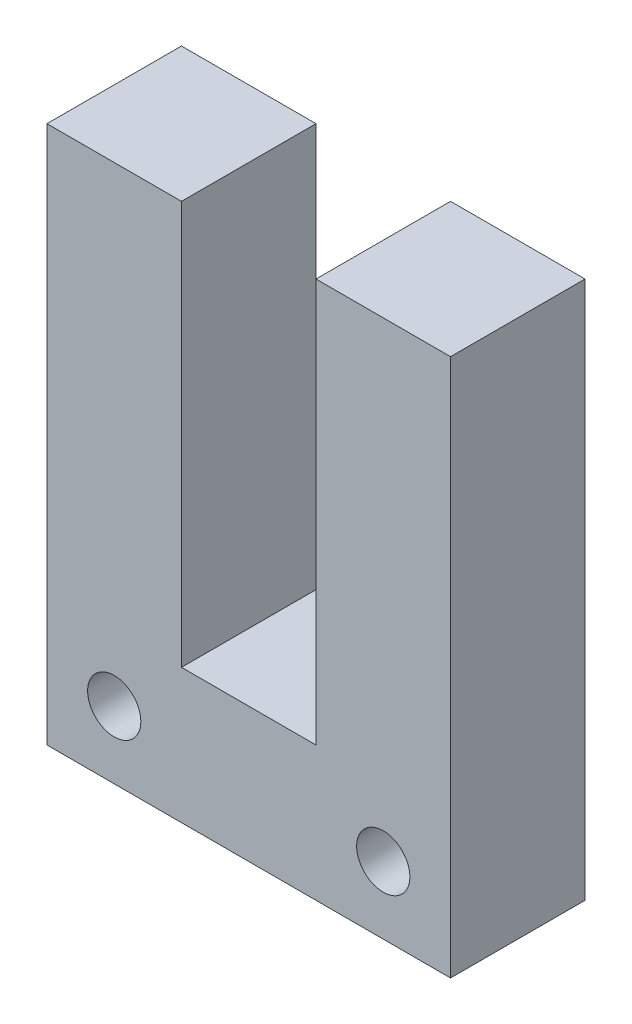
from build123d import *

# Parameters (mm, degrees)
SKETCH1_W        = 19.05
SKETCH1_H        = 25.4
MAIN_BLOCK_DEPTH = 6.35
SKETCH2_W        = 6.35
SKETCH2_H        = 19.05
U_CUT_DEPTH      = 12.7
SKETCH3_R        = 1.25603
BOLT_HOLES_DEPTH = 12.7


with BuildPart() as part:
    # Sketch1 → Main block (new body)
    with BuildSketch(Plane.XY):
        with Locations((9.525, 12.7)):
            Rectangle(SKETCH1_W, SKETCH1_H)
    extrude(amount=MAIN_BLOCK_DEPTH)

    # Sketch2 → U-cut (cut)
    with BuildSketch(Plane.XY.offset(6.35)):
        with Locations((9.525, 15.875)):
            Rectangle(SKETCH2_W, SKETCH2_H)
    extrude(amount=-U_CUT_DEPTH, mode=Mode.SUBTRACT)

    # Sketch3 → Bolt holes (cut)
    with BuildSketch(Plane.XY.offset(6.35)):
        with Locations((3.175, 3.175)):
            Circle(SKETCH3_R)
        with Locations((15.875, 3.175)):
            Circle(SKETCH3_R)
    extrude(amount=-BOLT_HOLES_DEPTH, mode=Mode.SUBTRACT)


solid = part.part
